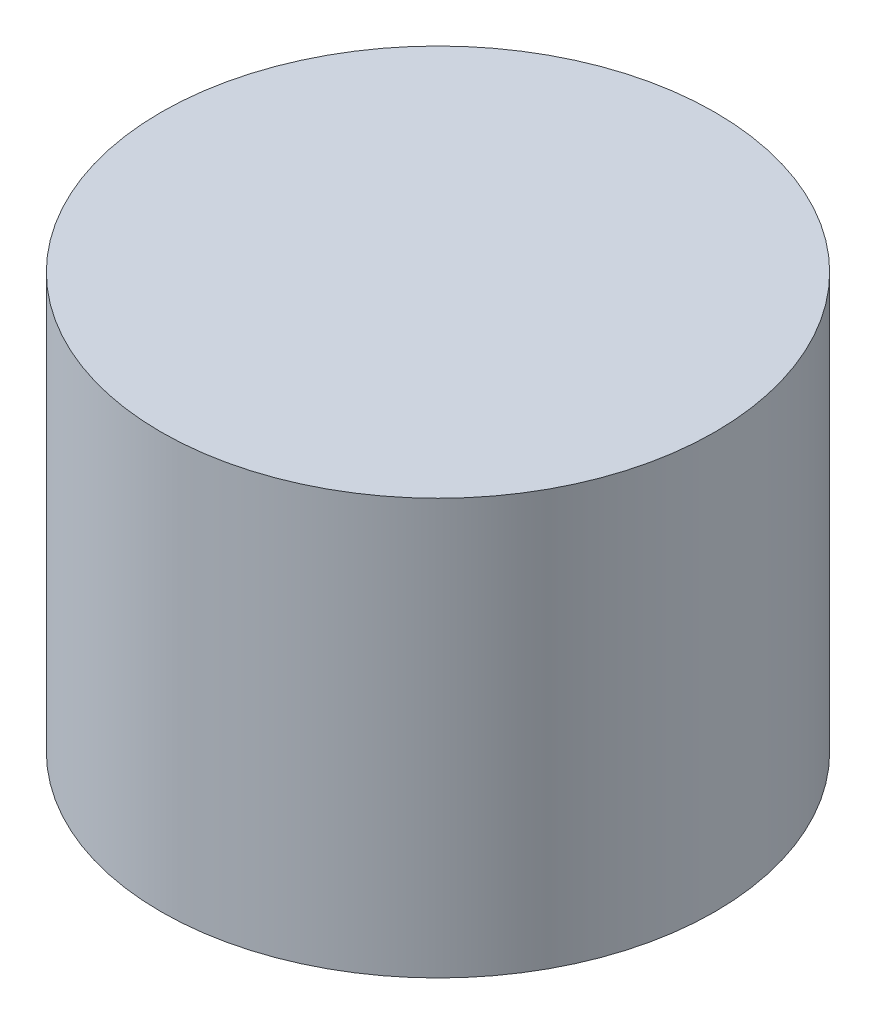
from build123d import *

# Parameters (mm, degrees)
SKETCH1_R           = 4
BOSS_EXTRUDE1_DEPTH = 6


with BuildPart() as part:
    # Sketch1 → Boss-Extrude1 (new body)
    with BuildSketch(Plane(origin=(0, 0, 0), x_dir=(1, 0, 0), z_dir=(0, 1, 0))):
        Circle(SKETCH1_R)
    extrude(amount=BOSS_EXTRUDE1_DEPTH)


solid = part.part
